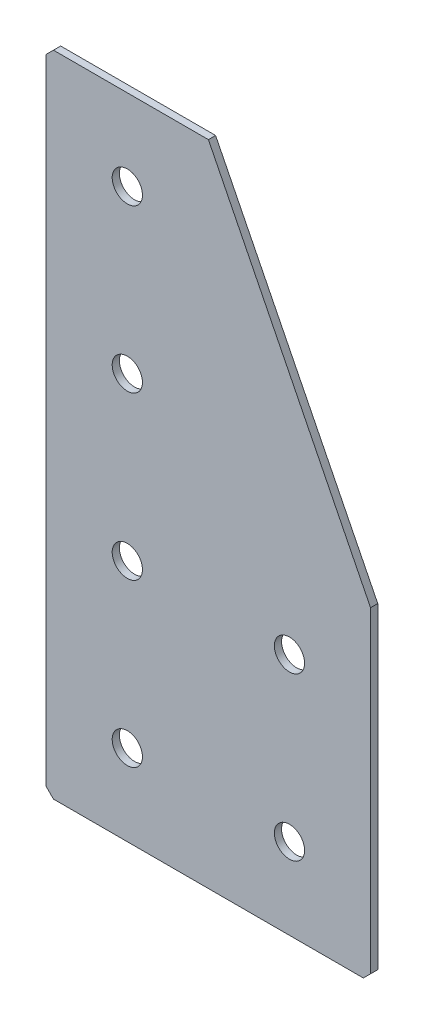
from build123d import *

# Parameters (mm, degrees)
EXTRUDE_1_DEPTH       = 2
HOLE_WIZARD_M81_D     = 8.4
HOLE_WIZARD_M81_DEPTH = 2
CHAMFER_1_SIZE        = 2


with BuildPart() as part:
    # Эскиз1 → Бобышка-Вытянуть1 (new body)
    with BuildSketch(Plane(origin=(0, 0, 0), x_dir=(1, 0, 0), z_dir=(0, 0, -1))):
        Polygon((0, 0), (0, 180), (90, 180), (90, 90), (45, 0), align=None)
    extrude(amount=EXTRUDE_1_DEPTH)

    # Отверстие с зазором M81
    with Locations(Plane(origin=(0, 0, -2), x_dir=(1, 0, 0), z_dir=(0, 0, -1))):
        with Locations((22.5, 157.5), (22.5, 112.5), (22.5, 67.5), (22.5, 22.5), (67.5, 157.5), (67.5, 112.5)):
            Hole(HOLE_WIZARD_M81_D / 2, depth=HOLE_WIZARD_M81_DEPTH)

    # Фаска1
    chamfer_1_edges = [part.edges().sort_by_distance(p)[0] for p in [
        (0, 0, -1),
        (0, -180, -1),
        (90, -180, -1),
    ]]
    chamfer(chamfer_1_edges, length=CHAMFER_1_SIZE)


solid = part.part
